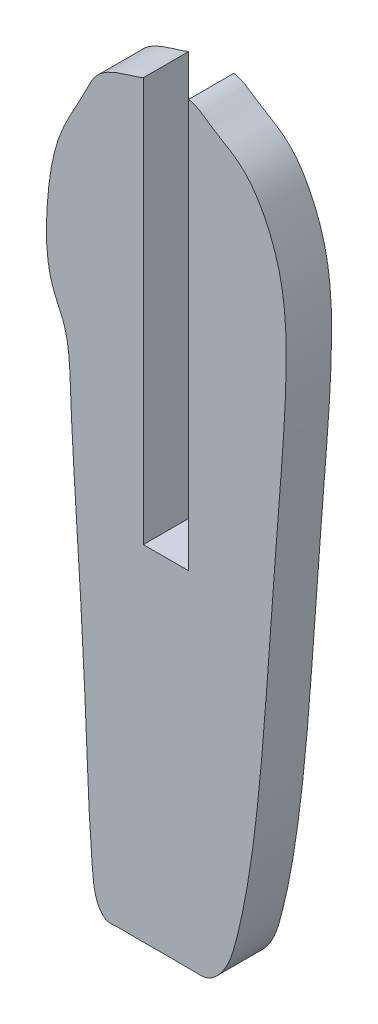
from build123d import *

# Parameters (mm, degrees)
BOSS_EXTRUDE2_DEPTH = 3


with BuildPart() as part:
    # Sketch1 → Boss-Extrude2 (new body)
    with BuildSketch(Plane.XY):
        with BuildLine():
            Line((2.2, 16.279886141), (2.2, -10.708761049))
            Line((2.2, -10.708761049), (-0.8, -10.708761049))
            Line((-0.8, -10.708761049), (-0.8, 16.018581102))
            add(Edge.make_bspline(
                [(-0.8, 16.018581102), (-1.137478868, 15.856785997), (-3.864968928, 15.186605333), (-4.464345742, 13.377021915), (-6.530482393, 10.160494645), (-7.096283176, 6.815456141), (-7.276733446, 3.649960029), (-7.010269398, 1.222073445), (-6.038575888, -0.500882297), (-5.672315374, -2.248417909), (-5.576049901, -5.964143668), (-5.121301969, -12.748224887), (-4.586958941, -21.777676866), (-4.398323748, -28.542556317), (-4.010513221, -32.493968256), (-3.492878576, -33.581179885), (-2.482192268, -33.43229003), (-1.975490972, -33.453616216), (-1.143003818, -33.466552535), (-0.596113192, -33.477610231), (0, -33.457446809)],
                knots=[0.027253246, 0.027253246, 0.027253246, 0.027253246, 0.046558941, 0.096384933, 0.158729393, 0.228185604, 0.271981863, 0.323080185, 0.351299809, 0.373137697, 0.414663231, 0.543428447, 0.725126089, 0.882497072, 0.894014183, 0.929959464, 0.943400874, 0.960682688, 0.966342601, 1, 1, 1, 1], degree=3))
            add(Edge.make_bspline(
                [(2.2, 16.279886141), (2.963118532, 16.08662731), (3.37996516, 15.559355614), (5.774968787, 14.354576548), (7.374628283, 12.062982525), (8.551573886, 8.672556745), (8.733915125, 3.818962641), (8.281107455, -2.674085455), (7.534372428, -11.853726278), (6.9584282, -21.373551103), (5.820926037, -28.748739461), (4.775625382, -32.303859485), (3.657435413, -33.423016219), (2.72816559, -33.486469625), (2.15503926, -33.45689106), (1.117698349, -33.457739351), (0.476348767, -33.461224782), (0, -33.457446809)],
                knots=[0.025934593, 0.025934593, 0.025934593, 0.025934593, 0.066182788, 0.102078434, 0.144598721, 0.209520588, 0.28142744, 0.39133428, 0.542219823, 0.751598654, 0.880094026, 0.919233947, 0.943979088, 0.94911048, 0.968165935, 0.97349308, 1, 1, 1, 1], degree=3))
        make_face()
    extrude(amount=BOSS_EXTRUDE2_DEPTH)


solid = part.part
